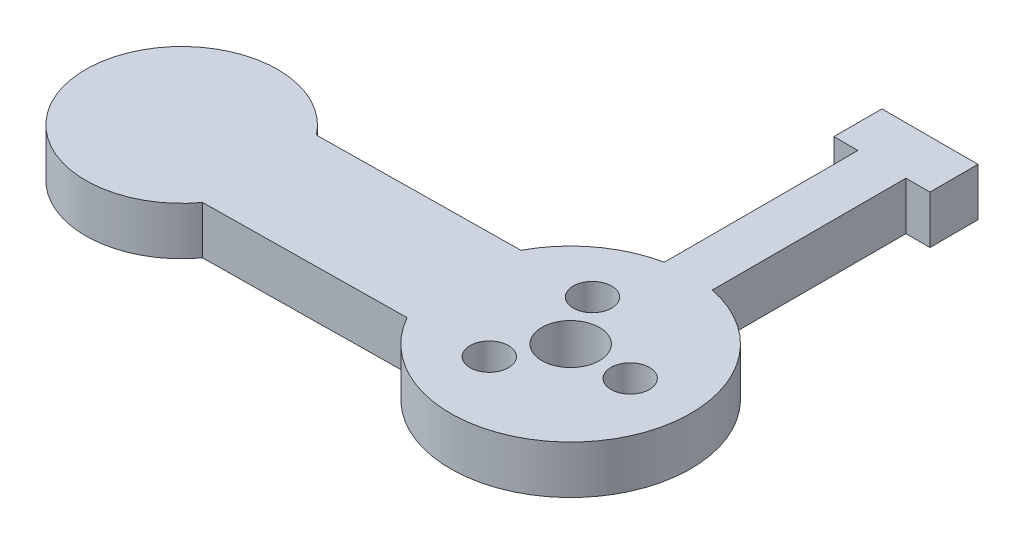
from build123d import *

# Parameters (mm, degrees)
SKETCH1_R           = 2
SKETCH1_R_2         = 3
BOSS_EXTRUDE1_DEPTH = 5


with BuildPart() as part:
    # Sketch1 → Boss-Extrude1 (new body)
    with BuildSketch(Plane(origin=(0, 0, 0), x_dir=(1, 0, 0), z_dir=(0, 1, 0))):
        with BuildLine():
            Line((-31.924309824, -6.390496245), (-10.891735709, -6.133522091))
            ThreePointArc((-10.891735709, -6.133522091), (10.102986142, -7.36068414), (2.5, 12.247448714))
            Line((2.5, 12.247448714), (2.5, 32.4))
            Line((2.5, 32.4), (5, 32.4))
            Line((5, 32.4), (5, 37.4))
            Line((5, 37.4), (-5, 37.4))
            Line((-5, 37.4), (-5, 32.4))
            Line((-5, 32.4), (-2.5, 32.4))
            Line((-2.5, 32.4), (-2.5, 12.247448714))
            ThreePointArc((-2.5, 12.247448714), (-7.483563, 10.012306668), (-11.038339719, 5.865582345))
            Line((-11.038339719, 5.865582345), (-32.070913834, 5.608608191))
            ThreePointArc((-32.070913834, 5.608608191), (-49.996268483, -0.610850042), (-31.924309824, -6.390496245))
        make_face()
        with Locations((6.2, 0)):
            Circle(SKETCH1_R, mode=Mode.SUBTRACT)
        with Locations((-3.1, -5.369357503)):
            Circle(SKETCH1_R, mode=Mode.SUBTRACT)
        Circle(SKETCH1_R_2, mode=Mode.SUBTRACT)
        with Locations((-3.1, 5.369357503)):
            Circle(SKETCH1_R, mode=Mode.SUBTRACT)
    extrude(amount=BOSS_EXTRUDE1_DEPTH)


solid = part.part
